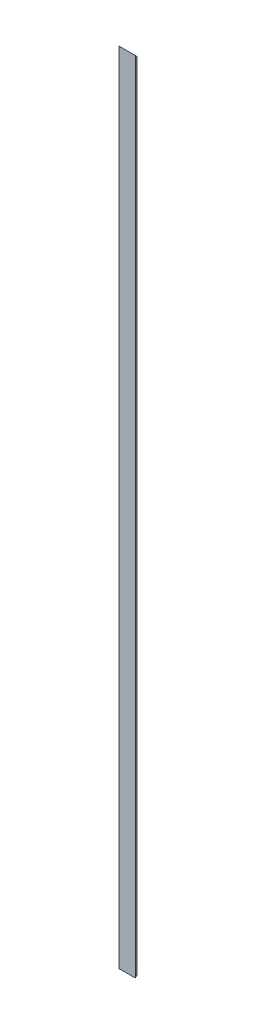
from build123d import *

# Parameters (mm, degrees)
EXTRUDE_1_DEPTH     = 2200
CUT_EXTRUDE_1_DEPTH = 46


with BuildPart() as part:
    # Эскиз1 → Вытянуть-Тонкостенный1 (new body)
    with BuildSketch(Plane(origin=(0, 0, 0), x_dir=(1, 0, 0), z_dir=(0, 1, 0))):
        Polygon((0, 45), (0, 0), (45, 0), (45, 5), (5, 5), (5, 45), align=None)
    extrude(amount=EXTRUDE_1_DEPTH)

    # Эскиз2 → Вырез-Вытянуть1 (cut, through all)
    with BuildSketch(Plane.ZY):
        Polygon((0, 0), (-45, 45), (-45, 0), align=None)
        Polygon((-45, 2200), (0, 2200), (-45, 2155), align=None)
    extrude(amount=-CUT_EXTRUDE_1_DEPTH, mode=Mode.SUBTRACT)


solid = part.part
